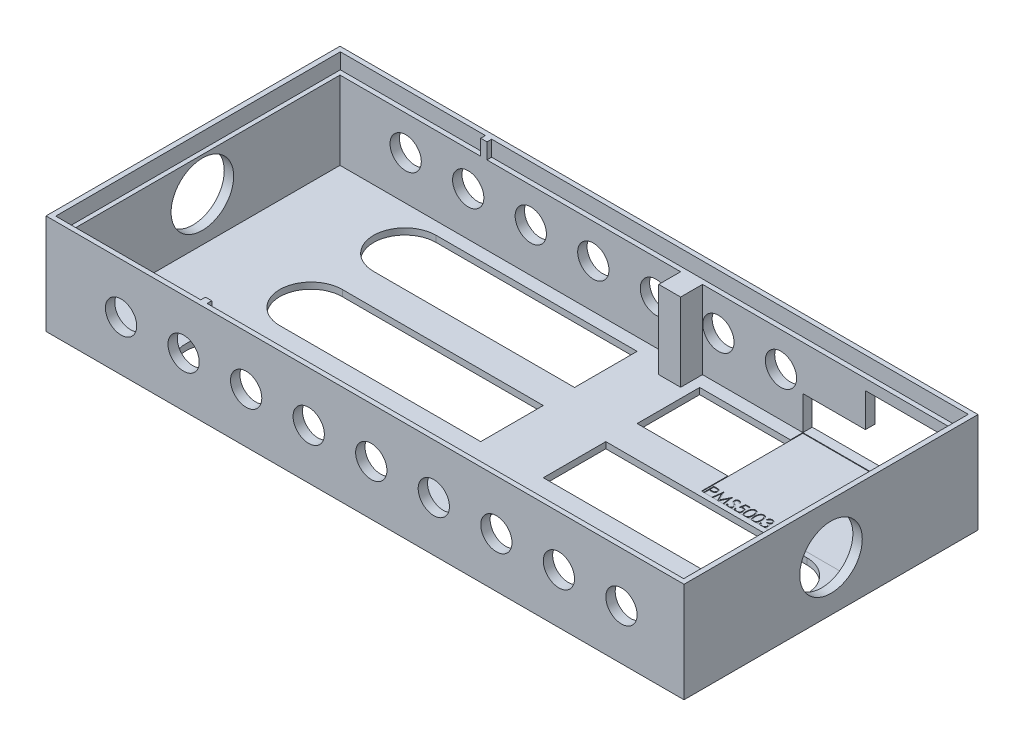
from build123d import *

# Parameters (mm, degrees)
CROQUIS1_W               = 202
CROQUIS1_H               = 93
CROQUIS1_W_2             = 198
CROQUIS1_H_2             = 88
SALIENTE_EXTRUIR2_DEPTH  = 25
CROQUIS3_W               = 202
CROQUIS3_H               = 93
SALIENTE_EXTRUIR3_DEPTH  = 2
CROQUIS4_W               = 204
CROQUIS4_H               = 94
CROQUIS4_W_2             = 202
CROQUIS4_H_2             = 93
SALIENTE_EXTRUIR5_DEPTH  = 27
CROQUIS5_W               = 204
CROQUIS5_H               = 94
CROQUIS5_W_2             = 200.789516826
CROQUIS5_H_2             = 91
SALIENTE_EXTRUIR6_DEPTH  = 5
CROQUIS6_W               = 2
CROQUIS6_H               = 1.5
SALIENTE_EXTRUIR7_DEPTH  = 5
CORTAR_EXTRUIR1_DEPTH    = 5
CORTAR_EXTRUIR2_DEPTH    = 25
CORTAR_EXTRUIR3_DEPTH    = 25
CROQUIS11_R              = 5
CORTAR_EXTRUIR4_DEPTH    = 100
CROQUIS12_W              = 15.882131831
CROQUIS12_H              = 10.610834241
SALIENTE_EXTRUIR9_DEPTH  = 3
CROQUIS13_W              = 20
CROQUIS13_H              = 20
CROQUIS13_H_2            = 10
SALIENTE_EXTRUIR10_DEPTH = 2
CROQUIS14_W              = 50
CROQUIS14_H              = 27.556851467
SALIENTE_EXTRUIR11_DEPTH = 2
CORTAR_EXTRUIR5_DEPTH    = 257
CROQUIS16_W              = 7
CROQUIS16_H              = 7
SALIENTE_EXTRUIR12_DEPTH = 25
CROQUIS17_W              = 1
CROQUIS17_H              = 1
SALIENTE_EXTRUIR13_DEPTH = 25
CROQUIS18_W              = 50
CROQUIS18_H              = 32.40471897
CORTAR_EXTRUIR6_DEPTH    = 0.2
CORTAR_EXTRUIR7_DEPTH    = 0.2


with BuildPart() as part:
    # Croquis1 → Saliente-Extruir2 (new body)
    with BuildSketch(Plane(origin=(0, 0, 0), x_dir=(1, 0, 0), z_dir=(0, 1, 0))):
        Rectangle(CROQUIS1_W, CROQUIS1_H)
        Rectangle(CROQUIS1_W_2, CROQUIS1_H_2, mode=Mode.SUBTRACT)
    extrude(amount=SALIENTE_EXTRUIR2_DEPTH)

    # Croquis3 → Saliente-Extruir3 (add)
    with BuildSketch(Plane.XZ):
        Rectangle(CROQUIS3_W, CROQUIS3_H)
    extrude(amount=SALIENTE_EXTRUIR3_DEPTH)

    # Croquis4 → Saliente-Extruir5 (add)
    with BuildSketch(Plane(origin=(0, 25, 0), x_dir=(1, 0, 0), z_dir=(0, 1, 0))):
        Rectangle(CROQUIS4_W, CROQUIS4_H)
        Rectangle(CROQUIS4_W_2, CROQUIS4_H_2, mode=Mode.SUBTRACT)
    extrude(amount=-SALIENTE_EXTRUIR5_DEPTH)

    # Croquis5 → Saliente-Extruir6 (add)
    with BuildSketch(Plane(origin=(0, 25, 0), x_dir=(1, 0, 0), z_dir=(0, 1, 0))):
        Rectangle(CROQUIS5_W, CROQUIS5_H)
        Rectangle(CROQUIS5_W_2, CROQUIS5_H_2, mode=Mode.SUBTRACT)
    extrude(amount=SALIENTE_EXTRUIR6_DEPTH)

    # Croquis6 → Saliente-Extruir7 (add)
    with BuildSketch(Plane(origin=(0, 25, 0), x_dir=(1, 0, 0), z_dir=(0, 1, 0))):
        with Locations((-53.002083315, -44.75)):
            Rectangle(CROQUIS6_W, CROQUIS6_H)
        with Locations((-53.002083315, 44.75)):
            Rectangle(CROQUIS6_W, CROQUIS6_H)
    extrude(amount=SALIENTE_EXTRUIR7_DEPTH)

    # Croquis8 → Cortar-Extruir1 (cut)
    with BuildSketch(Plane(origin=(0, 0, 0), x_dir=(1, 0, 0), z_dir=(0, 1, 0))):
        with BuildLine():
            Line((84.25, -10), (-64.25, -10))
            ThreePointArc((-64.25, -10), (-74.25, 0), (-64.25, 10))
            Line((-64.25, 10), (84.25, 10))
            ThreePointArc((84.25, 10), (94.25, 0), (84.25, -10))
        make_face()
        with BuildLine():
            Line((84.25, 20), (-64.25, 20))
            ThreePointArc((-64.25, 20), (-74.25, 30), (-64.25, 40))
            Line((-64.25, 40), (84.25, 40))
            ThreePointArc((84.25, 40), (94.25, 30), (84.25, 20))
        make_face()
        with BuildLine():
            Line((84.25, -40), (-64.25, -40))
            ThreePointArc((-64.25, -40), (-74.25, -30), (-64.25, -20))
            Line((-64.25, -20), (84.25, -20))
            ThreePointArc((84.25, -20), (94.25, -30), (84.25, -40))
        make_face()
    extrude(amount=-CORTAR_EXTRUIR1_DEPTH, mode=Mode.SUBTRACT)

    # Croquis9 → Cortar-Extruir2 (cut)
    with BuildSketch(Plane.XY.offset(-44)):
        Polygon((69, 0), (99, 0), (99, 21.623699886), (69, 21.623699886), (69, 1.623699886), align=None)
    extrude(amount=-CORTAR_EXTRUIR2_DEPTH, mode=Mode.SUBTRACT)

    # Croquis10 → Cortar-Extruir3 (cut)
    with BuildSketch(Plane.XY.offset(-44)):
        Polygon((49, 10.811849943), (49, 0), (59, 10.811849943), align=None)
        Polygon((49, 0), (69, 0), (69, 10.811849943), (59, 10.811849943), align=None)
    extrude(amount=-CORTAR_EXTRUIR3_DEPTH, mode=Mode.SUBTRACT)

    # Croquis11 → Cortar-Extruir4 (cut)
    with BuildSketch(Plane.XY.offset(47)):
        with Locations((82, 14)):
            Circle(CROQUIS11_R)
        with Locations((62, 14)):
            Circle(CROQUIS11_R)
        with Locations((42, 14)):
            Circle(CROQUIS11_R)
        with Locations((22, 14)):
            Circle(CROQUIS11_R)
        with Locations((2, 14)):
            Circle(CROQUIS11_R)
        with Locations((-18, 14)):
            Circle(CROQUIS11_R)
        with Locations((-38, 14)):
            Circle(CROQUIS11_R)
        with Locations((-58, 14)):
            Circle(CROQUIS11_R)
        with Locations((-78, 14)):
            Circle(CROQUIS11_R)
    extrude(amount=-CORTAR_EXTRUIR4_DEPTH, mode=Mode.SUBTRACT)

    # Croquis12 → Saliente-Extruir9 (add)
    with BuildSketch(Plane.XY.offset(-44)):
        with Locations((61.058934085, 16.117267064)):
            Rectangle(CROQUIS12_W, CROQUIS12_H)
    extrude(amount=-SALIENTE_EXTRUIR9_DEPTH)

    # Croquis13 → Saliente-Extruir10 (add)
    with BuildSketch(Plane(origin=(0, 0, 0), x_dir=(1, 0, 0), z_dir=(0, 1, 0))):
        with Locations((10, -30)):
            Rectangle(CROQUIS13_W, CROQUIS13_H)
        with Locations((10, -5)):
            Rectangle(CROQUIS13_W, CROQUIS13_H_2)
        with Locations((10, 5)):
            Rectangle(CROQUIS13_W, CROQUIS13_H_2)
        with Locations((10, 30)):
            Rectangle(CROQUIS13_W, CROQUIS13_H)
    extrude(amount=-SALIENTE_EXTRUIR10_DEPTH)

    # Croquis14 → Saliente-Extruir11 (add)
    with BuildSketch(Plane(origin=(0, 0, 0), x_dir=(1, 0, 0), z_dir=(0, 1, 0))):
        with Locations((74, 30.221574266)):
            Rectangle(CROQUIS14_W, CROQUIS14_H)
    extrude(amount=-SALIENTE_EXTRUIR11_DEPTH)

    # Croquis15 → Cortar-Extruir5 (cut)
    with BuildSketch(Plane(origin=(102, 0, 0), x_dir=(0, 0, -1), z_dir=(1, 0, 0))):
        with BuildLine():
            ThreePointArc((10, 14), (0, 24), (-10, 14))
            Line((-10, 14), (10, 14))
        make_face()
        with BuildLine():
            Line((10, 14), (-10, 14))
            ThreePointArc((-10, 14), (0, 4), (10, 14))
        make_face()
    extrude(amount=-CORTAR_EXTRUIR5_DEPTH, mode=Mode.SUBTRACT)

    # Croquis16 → Saliente-Extruir12 (add)
    with BuildSketch(Plane(origin=(0, 0, 0), x_dir=(1, 0, 0), z_dir=(0, 1, 0))):
        with Locations((13.41498244, 40.5)):
            Rectangle(CROQUIS16_W, CROQUIS16_H)
    extrude(amount=SALIENTE_EXTRUIR12_DEPTH)

    # Croquis17 → Saliente-Extruir13 (add)
    with BuildSketch(Plane(origin=(0, 0, 0), x_dir=(1, 0, 0), z_dir=(0, 1, 0))):
        with Locations((98.5, -43.5)):
            Rectangle(CROQUIS17_W, CROQUIS17_H)
    extrude(amount=SALIENTE_EXTRUIR13_DEPTH)

    # Croquis18 → Cortar-Extruir6 (cut)
    with BuildSketch(Plane(origin=(0, 0, 0), x_dir=(1, 0, 0), z_dir=(0, 1, 0))):
        with Locations((74, 27.797640515)):
            Rectangle(CROQUIS18_W, CROQUIS18_H)
    extrude(amount=-CORTAR_EXTRUIR6_DEPTH, mode=Mode.SUBTRACT)

    # Croquis19 → Cortar-Extruir7 (cut)
    with BuildSketch(Plane(origin=(0, -0.2, 0), x_dir=(1, 0, 0), z_dir=(0, 1, 0))):
        with BuildLine():
            Line((49.448717949, 15.09528103), (50.135116186, 15.09528103))
            add(Edge.make_bspline(
                [(50.135116186, 15.09528103), (50.182327092, 15.095229134), (50.272785285, 15.095129698), (50.402500341, 15.092114952), (50.520310072, 15.08808826), (50.625960453, 15.082506367), (50.719776551, 15.075909777), (50.801333851, 15.066657738), (50.871273407, 15.056997442), (50.913179857, 15.047176036), (50.932291667, 15.042696895)],
                knots=[0, 0, 0, 0, 0.000141628, 0.000271366, 0.00038923, 0.000495248, 0.00058876, 0.000671296, 0.000741499, 0.00080036, 0.00080036, 0.00080036, 0.00080036], degree=3))
            add(Edge.make_bspline(
                [(50.932291667, 15.042696895), (50.9564852, 15.036074946), (51.004302178, 15.022987084), (51.073203221, 14.99677336), (51.138757066, 14.965691195), (51.201188625, 14.930267255), (51.259730708, 14.888981691), (51.315256749, 14.843508073), (51.367276729, 14.792796505), (51.415498121, 14.737415765), (51.459782918, 14.678295555), (51.497912601, 14.614553325), (51.529839828, 14.547262022), (51.5572231, 14.476468451), (51.576931554, 14.401578127), (51.591778454, 14.323111415), (51.601202082, 14.241076725), (51.602104643, 14.185016857), (51.602564103, 14.156478947)],
                knots=[0, 0, 0, 0, 7.5216e-05, 0.00014866, 0.000220794, 0.000292713, 0.000363707, 0.000435434, 0.000507823, 0.000581364, 0.000655543, 0.000729131, 0.000803767, 0.000878771, 0.000956497, 0.001035702, 0.001118238, 0.001203821, 0.001203821, 0.001203821, 0.001203821], degree=3))
            add(Edge.make_bspline(
                [(51.602564103, 14.156478947), (51.602142678, 14.12770117), (51.601318132, 14.071395506), (51.591421847, 13.989022718), (51.578091655, 13.910304328), (51.557594603, 13.835414877), (51.53074893, 13.764799107), (51.499256877, 13.697377875), (51.461273346, 13.634298203), (51.417628517, 13.575331085), (51.369076922, 13.520421173), (51.315823984, 13.469966378), (51.258084692, 13.42426204), (51.196042543, 13.383205696), (51.129092695, 13.347749417), (51.058250541, 13.315992112), (50.982900325, 13.289321051), (50.930757811, 13.27529099), (50.904246795, 13.268157633)],
                knots=[0, 0, 0, 0, 8.6284e-05, 0.00016882, 0.000248587, 0.000325638, 0.000401297, 0.000474998, 0.000548586, 0.000621785, 0.0006948, 0.0007682, 0.000841564, 0.000915458, 0.000991056, 0.00106858, 0.00114819, 0.001230532, 0.001230532, 0.001230532, 0.001230532], degree=3))
            add(Edge.make_bspline(
                [(50.904246795, 13.268157633), (50.882319461, 13.263494652), (50.834264434, 13.253275457), (50.755121711, 13.241867001), (50.662976325, 13.2321294), (50.557954045, 13.224828262), (50.440149141, 13.218577894), (50.309497883, 13.2136098), (50.165743806, 13.210879946), (50.065472562, 13.210739153), (50.013120994, 13.210665645)],
                knots=[0, 0, 0, 0, 6.7238e-05, 0.000147357, 0.000239727, 0.000345177, 0.000463135, 0.000593636, 0.000737393, 0.000894446, 0.000894446, 0.000894446, 0.000894446], degree=3))
            Line((50.013120994, 13.210665645), (49.762820513, 13.210665645))
            Line((49.762820513, 13.210665645), (49.762820513, 11.59528103))
            Line((49.762820513, 11.59528103), (49.448717949, 11.59528103))
            Line((49.448717949, 11.59528103), (49.448717949, 15.09528103))
        make_face()
        with BuildLine():
            Line((49.762820513, 14.736306671), (49.762820513, 13.569640004))
            Line((49.762820513, 13.569640004), (50.375600962, 13.561927665))
            add(Edge.make_bspline(
                [(50.375600962, 13.561927665), (50.405520887, 13.561912201), (50.463280687, 13.561882349), (50.546716911, 13.565867572), (50.624126198, 13.570468105), (50.695270773, 13.577204029), (50.760182708, 13.586725286), (50.818970237, 13.596337024), (50.871177519, 13.610242387), (50.932276721, 13.628965456), (51.000360069, 13.660898071), (51.074427617, 13.707247961), (51.137198204, 13.76632867), (51.1915165, 13.832756501), (51.234622378, 13.90665563), (51.266178371, 13.985724567), (51.284719528, 14.069152417), (51.287205722, 14.126240555), (51.288461538, 14.155076703)],
                knots=[0, 0, 0, 0, 8.9746e-05, 0.000173253, 0.000250533, 0.00032239, 0.000387534, 0.00044736, 0.000500926, 0.000549486, 0.000638903, 0.000725641, 0.000810488, 0.000896226, 0.000982324, 0.00106604, 0.001150757, 0.001237226, 0.001237226, 0.001237226, 0.001237226], degree=3))
            add(Edge.make_bspline(
                [(51.288461538, 14.155076703), (51.287198892, 14.183215217), (51.284688907, 14.239151099), (51.266033044, 14.321129859), (51.23468373, 14.399365564), (51.191227135, 14.472338649), (51.138486006, 14.538527453), (51.077186662, 14.59602458), (51.007473401, 14.642246283), (50.94262517, 14.672079564), (50.885023984, 14.69029484), (50.834992024, 14.70303968), (50.77850135, 14.713215287), (50.71553357, 14.721454789), (50.646576736, 14.728508251), (50.571038421, 14.733294228), (50.489204778, 14.736095684), (50.432394207, 14.736234639), (50.402944712, 14.736306671)],
                knots=[0, 0, 0, 0, 8.4371e-05, 0.000167719, 0.000250783, 0.000336277, 0.000421575, 0.000503926, 0.000587348, 0.000671427, 0.000717102, 0.000768457, 0.000826213, 0.000889178, 0.000958942, 0.001034123, 0.001116202, 0.001204546, 0.001204546, 0.001204546, 0.001204546], degree=3))
            Line((50.402944712, 14.736306671), (49.762820513, 14.736306671))
        make_face(mode=Mode.SUBTRACT)
        Polygon((52.141025641, 11.59528103), (52.603064904, 15.09528103), (52.647936699, 15.09528103), (54.092948718, 12.223486158), (55.534455128, 15.09528103), (55.580028045, 15.09528103), (56.044871795, 11.59528103), (55.729366987, 11.59528103), (55.394230769, 14.113710517), (54.130809295, 11.59528103), (54.059995994, 11.59528103), (52.791666667, 14.119319492), (52.457231571, 11.59528103), align=None)
        with BuildLine():
            Line((56.403846154, 12.270461319), (56.699719551, 12.447845133))
            add(Edge.make_bspline(
                [(56.699719551, 12.447845133), (56.727237789, 12.401780748), (56.779961669, 12.313523164), (56.867913028, 12.194265123), (56.959045939, 12.092902967), (57.054035273, 12.010026359), (57.152301221, 11.944777472), (57.254485275, 11.898575241), (57.360243086, 11.869759265), (57.432216907, 11.866259179), (57.468149038, 11.864511799)],
                knots=[0, 0, 0, 0, 0.000160901, 0.00030828, 0.000443778, 0.00056903, 0.000685513, 0.000796284, 0.00090427, 0.001011928, 0.001011928, 0.001011928, 0.001011928], degree=3))
            add(Edge.make_bspline(
                [(57.468149038, 11.864511799), (57.498835899, 11.865366472), (57.559672672, 11.867060862), (57.649234915, 11.883341664), (57.736216717, 11.908353793), (57.818825355, 11.944174725), (57.89592097, 11.98751321), (57.963527665, 12.039859388), (58.021973778, 12.098465593), (58.069782893, 12.163848248), (58.106462928, 12.234165397), (58.134654996, 12.306341348), (58.15030007, 12.381509916), (58.152656823, 12.432120379), (58.153846154, 12.457660838)],
                knots=[0, 0, 0, 0, 9.1978e-05, 0.000182347, 0.000272202, 0.000362975, 0.000451852, 0.000536835, 0.000618639, 0.000699414, 0.000778765, 0.000855983, 0.0009312, 0.001007828, 0.001007828, 0.001007828, 0.001007828], degree=3))
            add(Edge.make_bspline(
                [(58.153846154, 12.457660838), (58.152371843, 12.486801687), (58.149374785, 12.546040777), (58.124043305, 12.63344043), (58.084194058, 12.719933), (58.047431414, 12.773434265), (58.028345353, 12.801210517)],
                knots=[0, 0, 0, 0, 8.7281e-05, 0.000177429, 0.000270909, 0.000371844, 0.000371844, 0.000371844, 0.000371844], degree=3))
            add(Edge.make_bspline(
                [(58.028345353, 12.801210517), (58.012674738, 12.821257341), (57.979776244, 12.863343139), (57.923218732, 12.925988375), (57.856852617, 12.990606794), (57.782949062, 13.059665851), (57.698815973, 13.129953647), (57.607088459, 13.204821925), (57.5054246, 13.281423502), (57.434125103, 13.332796068), (57.397335737, 13.359303466)],
                knots=[0, 0, 0, 0, 7.6319e-05, 0.000160223, 0.000252933, 0.000354147, 0.000463581, 0.000581729, 0.000709336, 0.000845369, 0.000845369, 0.000845369, 0.000845369], degree=3))
            add(Edge.make_bspline(
                [(57.397335737, 13.359303466), (57.360511741, 13.385532054), (57.290107064, 13.435679116), (57.191648482, 13.5101034), (57.103604019, 13.578147269), (57.026365003, 13.640451281), (56.959965406, 13.697023886), (56.903881995, 13.747321825), (56.859543438, 13.792705386), (56.834887857, 13.822146728), (56.823818109, 13.835365165)],
                knots=[0, 0, 0, 0, 0.000135623, 0.000259301, 0.000370234, 0.000469439, 0.00055697, 0.000631911, 0.000695377, 0.00074709, 0.00074709, 0.00074709, 0.00074709], degree=3))
            add(Edge.make_bspline(
                [(56.823818109, 13.835365165), (56.808345564, 13.855966202), (56.777916727, 13.896480905), (56.737750722, 13.959805763), (56.703611559, 14.024629028), (56.676849227, 14.091124893), (56.654313008, 14.158359822), (56.639155077, 14.227211068), (56.62966368, 14.297369686), (56.628691694, 14.344583187), (56.628205128, 14.368217729)],
                knots=[0, 0, 0, 0, 7.727e-05, 0.000151962, 0.000224716, 0.000296717, 0.00036678, 0.0004372, 0.000507902, 0.000578771, 0.000578771, 0.000578771, 0.000578771], degree=3))
            add(Edge.make_bspline(
                [(56.628205128, 14.368217729), (56.629510337, 14.405247503), (56.632092857, 14.478515567), (56.653933375, 14.585546398), (56.688406268, 14.687732815), (56.736701156, 14.784063148), (56.798958509, 14.872029129), (56.871004483, 14.952642616), (56.95681597, 15.020411199), (57.050968593, 15.079623257), (57.154024965, 15.125969182), (57.262015868, 15.160930162), (57.37511294, 15.18073942), (57.451716075, 15.183582185), (57.490584936, 15.18502462)],
                knots=[0, 0, 0, 0, 0.000110999, 0.000219625, 0.000326272, 0.00043382, 0.000541574, 0.000648775, 0.000756959, 0.000868438, 0.000981703, 0.00109501, 0.001208203, 0.0013248, 0.0013248, 0.0013248, 0.0013248], degree=3))
            add(Edge.make_bspline(
                [(57.490584936, 15.18502462), (57.531829036, 15.183602068), (57.613850388, 15.180773067), (57.734499604, 15.156175536), (57.85066032, 15.115474864), (57.944103585, 15.069286206), (58.017236346, 15.02315479), (58.073009079, 14.981134966), (58.12952653, 14.932759857), (58.187244584, 14.877900611), (58.245185244, 14.81605386), (58.304208696, 14.747643171), (58.364452965, 14.673086615), (58.403208825, 14.619862115), (58.423076923, 14.592576703)],
                knots=[0, 0, 0, 0, 0.000123638, 0.000245877, 0.000367608, 0.000492088, 0.000557638, 0.000626769, 0.000701372, 0.00078072, 0.000865532, 0.000955497, 0.001051745, 0.001152989, 0.001152989, 0.001152989, 0.001152989], degree=3))
            Line((58.423076923, 14.592576703), (58.139122596, 14.377332312))
            add(Edge.make_bspline(
                [(58.139122596, 14.377332312), (58.121976664, 14.399421003), (58.088957607, 14.441958656), (58.03882812, 14.501529971), (57.991579472, 14.555946451), (57.945029072, 14.603211579), (57.901635441, 14.645913712), (57.859518398, 14.682473469), (57.819284047, 14.713249065), (57.768567136, 14.746092624), (57.704849418, 14.778649128), (57.624864882, 14.806198206), (57.541278607, 14.822753268), (57.484348975, 14.824942156), (57.455528846, 14.826050261)],
                knots=[0, 0, 0, 0, 8.3877e-05, 0.000161528, 0.000233552, 0.000299993, 0.000360485, 0.000416152, 0.000467195, 0.000512312, 0.000597287, 0.000681099, 0.000765389, 0.000851809, 0.000851809, 0.000851809, 0.000851809], degree=3))
            add(Edge.make_bspline(
                [(57.455528846, 14.826050261), (57.419372324, 14.824838561), (57.349647876, 14.822501912), (57.25065764, 14.796981926), (57.161563715, 14.756800066), (57.08501115, 14.700485088), (57.021274173, 14.633764095), (56.975168714, 14.55698524), (56.94741855, 14.472202838), (56.94403227, 14.413061181), (56.942307692, 14.382941286)],
                knots=[0, 0, 0, 0, 0.000108248, 0.000208746, 0.00030443, 0.000399793, 0.000492054, 0.00057947, 0.000666386, 0.000756591, 0.000756591, 0.000756591, 0.000756591], degree=3))
            add(Edge.make_bspline(
                [(56.942307692, 14.382941286), (56.942700819, 14.364189808), (56.943487715, 14.326656188), (56.954462513, 14.271204767), (56.968561842, 14.215893427), (56.990904473, 14.160970844), (57.021749777, 14.105476485), (57.062254953, 14.048454748), (57.113268265, 13.989403039), (57.152345277, 13.950995665), (57.172976763, 13.930717729)],
                knots=[0, 0, 0, 0, 5.616e-05, 0.000112411, 0.000169046, 0.000227244, 0.000289691, 0.000359134, 0.000436702, 0.000523463, 0.000523463, 0.000523463, 0.000523463], degree=3))
            add(Edge.make_bspline(
                [(57.172976763, 13.930717729), (57.180638135, 13.923880703), (57.198839802, 13.907637495), (57.232115728, 13.881045214), (57.276058526, 13.848242442), (57.329520728, 13.807655125), (57.393488089, 13.760573663), (57.467967645, 13.707600051), (57.552129178, 13.647014592), (57.611851094, 13.604657051), (57.643429487, 13.582260197)],
                knots=[0, 0, 0, 0, 3.0802e-05, 7.3177e-05, 0.000127725, 0.000195314, 0.000274544, 0.000365991, 0.000469501, 0.000585644, 0.000585644, 0.000585644, 0.000585644], degree=3))
            add(Edge.make_bspline(
                [(57.643429487, 13.582260197), (57.6814154, 13.554618837), (57.754969857, 13.501095175), (57.859627437, 13.420679495), (57.954521245, 13.342031727), (58.039984448, 13.26565412), (58.116861357, 13.192126027), (58.184299078, 13.120562846), (58.242984758, 13.051477274), (58.306163976, 12.962904698), (58.370721796, 12.854123614), (58.426163303, 12.720845375), (58.461121651, 12.587049055), (58.465693166, 12.497122218), (58.467948718, 12.452752985)],
                knots=[0, 0, 0, 0, 0.000140932, 0.000272896, 0.000395881, 0.000510584, 0.000616697, 0.000714904, 0.000805482, 0.000888372, 0.001041088, 0.001183793, 0.001320341, 0.001453327, 0.001453327, 0.001453327, 0.001453327], degree=3))
            add(Edge.make_bspline(
                [(58.467948718, 12.452752985), (58.46729158, 12.42137462), (58.465990065, 12.359227237), (58.451029151, 12.26797216), (58.429109486, 12.17934129), (58.396072252, 12.094430178), (58.355749094, 12.011685415), (58.304582846, 11.933277514), (58.245275161, 11.857471116), (58.177241396, 11.786287624), (58.102795494, 11.720941429), (58.024111799, 11.662812367), (57.941061526, 11.614344044), (57.854095209, 11.574793202), (57.763192873, 11.543859684), (57.668385089, 11.521446815), (57.569515578, 11.507691104), (57.502315096, 11.506263343), (57.468149038, 11.50553744)],
                knots=[0, 0, 0, 0, 9.4044e-05, 0.000186263, 0.000276729, 0.000367488, 0.000459046, 0.000552398, 0.000647774, 0.000747454, 0.000847311, 0.000944634, 0.001040472, 0.001135227, 0.001230788, 0.001328063, 0.00142712, 0.00152957, 0.00152957, 0.00152957, 0.00152957], degree=3))
            add(Edge.make_bspline(
                [(57.468149038, 11.50553744), (57.441713695, 11.506048622), (57.389175935, 11.507064547), (57.311466454, 11.516045828), (57.235326864, 11.528752931), (57.161712582, 11.548927001), (57.089675171, 11.573403978), (57.019527936, 11.603542311), (56.951236882, 11.639659512), (56.884419299, 11.680954537), (56.819245125, 11.729012282), (56.756325657, 11.784985778), (56.693596471, 11.847331283), (56.632909075, 11.917741846), (56.573035931, 11.995079929), (56.515157521, 12.080069113), (56.458075804, 12.172246466), (56.422260336, 12.237111552), (56.403846154, 12.270461319)],
                knots=[0, 0, 0, 0, 7.9276e-05, 0.000157554, 0.000234438, 0.000310629, 0.000386236, 0.000462555, 0.000539392, 0.000617798, 0.000698008, 0.000781971, 0.000870217, 0.00096315, 0.001060616, 0.001163492, 0.001271478, 0.00138575, 0.00138575, 0.00138575, 0.00138575], degree=3))
        make_face()
        with BuildLine():
            Line((61.070512821, 15.09528103), (61.070512821, 14.736306671))
            Line((61.070512821, 14.736306671), (59.880008013, 14.736306671))
            Line((59.880008013, 14.736306671), (59.69140625, 13.815733754))
            add(Edge.make_bspline(
                [(59.69140625, 13.815733754), (59.728462124, 13.825964026), (59.80025202, 13.84578356), (59.906211881, 13.86778933), (60.006804085, 13.881054774), (60.072079455, 13.882866085), (60.103665865, 13.883742569)],
                knots=[0, 0, 0, 0, 0.000115302, 0.000223379, 0.000324431, 0.000419176, 0.000419176, 0.000419176, 0.000419176], degree=3))
            add(Edge.make_bspline(
                [(60.103665865, 13.883742569), (60.142749605, 13.882896633), (60.219598002, 13.881233312), (60.332036949, 13.865261462), (60.439369843, 13.840121548), (60.541372213, 13.805001026), (60.638232763, 13.760091293), (60.729060325, 13.703991353), (60.815218238, 13.638458021), (60.895160832, 13.563113009), (60.96768514, 13.480191393), (61.03145113, 13.391033522), (61.08561372, 13.296505859), (61.129174475, 13.195705251), (61.163958809, 13.089746097), (61.187110804, 12.977513515), (61.202527513, 12.860065395), (61.204249899, 12.779760825), (61.205128205, 12.738810677)],
                knots=[0, 0, 0, 0, 0.00011719, 0.000230425, 0.000339944, 0.000447481, 0.000553499, 0.000659556, 0.000767111, 0.000877722, 0.000988528, 0.001097091, 0.001206056, 0.001314692, 0.001425996, 0.001539995, 0.001658004, 0.001780798, 0.001780798, 0.001780798, 0.001780798], degree=3))
            add(Edge.make_bspline(
                [(61.205128205, 12.738810677), (61.20446313, 12.710288457), (61.203141967, 12.65362947), (61.19642338, 12.569485269), (61.183487664, 12.487122436), (61.166119939, 12.406530044), (61.143577521, 12.327860672), (61.116288468, 12.250889144), (61.08289244, 12.176094537), (61.046261065, 12.102769142), (61.005014587, 12.032570635), (60.959236079, 11.966921648), (60.910870588, 11.904837367), (60.858829203, 11.846983634), (60.802628208, 11.793740616), (60.742948241, 11.744792334), (60.680265522, 11.699311004), (60.613610279, 11.659142809), (60.544467796, 11.622179853), (60.471839579, 11.591856315), (60.397378879, 11.564745787), (60.320014003, 11.54313626), (60.239920191, 11.526203705), (60.156965415, 11.514703105), (60.071584745, 11.506326667), (60.013709733, 11.50580231), (59.98447516, 11.50553744)],
                knots=[0, 0, 0, 0, 8.5583e-05, 0.000170009, 0.000253005, 0.000335518, 0.000417186, 0.000498352, 0.000580291, 0.000662755, 0.000744161, 0.000824288, 0.000902692, 0.000980133, 0.001057498, 0.001134702, 0.00121156, 0.001289599, 0.001368002, 0.001446531, 0.001525481, 0.001605609, 0.001687289, 0.001770875, 0.001856759, 0.001944425, 0.001944425, 0.001944425, 0.001944425], degree=3))
            add(Edge.make_bspline(
                [(59.98447516, 11.50553744), (59.94960098, 11.506228278), (59.880990149, 11.50758742), (59.780469582, 11.521805906), (59.683754976, 11.542169822), (59.591624875, 11.572806092), (59.503253611, 11.611193387), (59.419830893, 11.659709558), (59.339225117, 11.714688662), (59.264713081, 11.779569015), (59.195556967, 11.850484697), (59.133650458, 11.927442338), (59.078516882, 12.00917178), (59.031039135, 12.096069934), (58.990541113, 12.187908465), (58.958726125, 12.285031466), (58.93304777, 12.38693147), (58.92218435, 12.45708498), (58.916666667, 12.492716927)],
                knots=[0, 0, 0, 0, 0.000104552, 0.000205693, 0.000304023, 0.000400691, 0.00049644, 0.000592535, 0.000689779, 0.000788716, 0.000888377, 0.000986596, 0.001084603, 0.001183757, 0.001283279, 0.001385267, 0.001490017, 0.001598135, 0.001598135, 0.001598135, 0.001598135], degree=3))
            Line((58.916666667, 12.492716927), (59.230769231, 12.492716927))
            add(Edge.make_bspline(
                [(59.230769231, 12.492716927), (59.238497788, 12.459340475), (59.253352505, 12.39518908), (59.285958253, 12.305057739), (59.325824129, 12.224738515), (59.373228477, 12.153168932), (59.429778508, 12.090759935), (59.494307937, 12.035142873), (59.56665566, 11.984967743), (59.647048889, 11.943144976), (59.731861969, 11.907476223), (59.820629179, 11.883724528), (59.910933525, 11.867023635), (59.972011895, 11.865351874), (60.002704327, 11.864511799)],
                knots=[0, 0, 0, 0, 0.000102709, 0.000197412, 0.000286774, 0.000371169, 0.000454082, 0.000538572, 0.000626283, 0.000717552, 0.000809994, 0.00090168, 0.00099274, 0.001084718, 0.001084718, 0.001084718, 0.001084718], degree=3))
            add(Edge.make_bspline(
                [(60.002704327, 11.864511799), (60.032662771, 11.865332577), (60.091651194, 11.866948696), (60.17846258, 11.879387708), (60.262275454, 11.898545279), (60.342262811, 11.927215134), (60.419824351, 11.962059852), (60.492998121, 12.006774928), (60.563900998, 12.058234947), (60.630329132, 12.117191577), (60.691168581, 12.182161271), (60.744924702, 12.251638665), (60.789701616, 12.325755511), (60.827435725, 12.403228664), (60.856089023, 12.484907221), (60.876530005, 12.570408397), (60.888533063, 12.659943377), (60.890184243, 12.721012686), (60.891025641, 12.752131992)],
                knots=[0, 0, 0, 0, 8.9842e-05, 0.0001769, 0.000262612, 0.000347317, 0.000431396, 0.000517249, 0.000604055, 0.000693954, 0.000783242, 0.000870748, 0.000956963, 0.001042571, 0.001128832, 0.00121607, 0.001305907, 0.001399251, 0.001399251, 0.001399251, 0.001399251], degree=3))
            add(Edge.make_bspline(
                [(60.891025641, 12.752131992), (60.890367162, 12.780207743), (60.889078282, 12.835162032), (60.878547711, 12.915561239), (60.860230739, 12.991634281), (60.834806859, 13.063748515), (60.802527351, 13.131971957), (60.763081039, 13.196375018), (60.715727641, 13.256108851), (60.661635753, 13.311201404), (60.602377712, 13.362046279), (60.536933969, 13.405390366), (60.466674042, 13.441854283), (60.392444443, 13.473322282), (60.312479544, 13.495923027), (60.228362912, 13.512890913), (60.139186204, 13.522706275), (60.078215516, 13.524068164), (60.046875, 13.52476821)],
                knots=[0, 0, 0, 0, 8.4208e-05, 0.000164824, 0.000242709, 0.000318547, 0.000393815, 0.000468731, 0.000544614, 0.00062196, 0.000700062, 0.000778428, 0.000856831, 0.000937299, 0.001019835, 0.001105635, 0.00119452, 0.001288536, 0.001288536, 0.001288536, 0.001288536], degree=3))
            add(Edge.make_bspline(
                [(60.046875, 13.52476821), (60.019746071, 13.524187618), (59.963731716, 13.522988845), (59.877808889, 13.514162348), (59.787517166, 13.499923054), (59.693202671, 13.480336806), (59.594582163, 13.454705729), (59.491863762, 13.423991229), (59.384831495, 13.38726923), (59.312713771, 13.359537016), (59.275641026, 13.34528103)],
                knots=[0, 0, 0, 0, 8.1378e-05, 0.000168026, 0.000258858, 0.000355524, 0.000456875, 0.000564457, 0.000677092, 0.000796243, 0.000796243, 0.000796243, 0.000796243], degree=3))
            Line((59.275641026, 13.34528103), (59.634615385, 15.09528103))
            Line((59.634615385, 15.09528103), (61.070512821, 15.09528103))
        make_face()
        with BuildLine():
            add(Edge.make_bspline(
                [(61.564102564, 13.343878786), (61.564430582, 13.399976174), (61.565067762, 13.508946158), (61.572156183, 13.667730801), (61.583931526, 13.81669109), (61.600068898, 13.955834156), (61.619706879, 14.08519592), (61.645922365, 14.204430677), (61.675735168, 14.314090284), (61.710287614, 14.414532332), (61.749275403, 14.507110035), (61.791709663, 14.593535237), (61.839274458, 14.673677169), (61.889251371, 14.748814959), (61.943663442, 14.817718654), (62.000962233, 14.881361317), (62.063384109, 14.938272067), (62.128807117, 14.99011837), (62.197823582, 15.035567841), (62.268466248, 15.07560058), (62.341221354, 15.109800447), (62.416287537, 15.136690883), (62.492990095, 15.15890173), (62.571597161, 15.174090677), (62.652238525, 15.183647586), (62.70666996, 15.184561254), (62.73427484, 15.18502462)],
                knots=[0, 0, 0, 0, 0.000168282, 0.000326891, 0.000476705, 0.00061646, 0.000747059, 0.00086904, 0.000982494, 0.001087814, 0.001187428, 0.001283689, 0.001376399, 0.001466822, 0.001554203, 0.001639568, 0.001723424, 0.001807301, 0.001889751, 0.001971063, 0.002050735, 0.002130583, 0.002210036, 0.002290062, 0.002370508, 0.002453288, 0.002453288, 0.002453288, 0.002453288], degree=3))
            add(Edge.make_bspline(
                [(62.73427484, 15.18502462), (62.762110318, 15.184536805), (62.817466327, 15.183566694), (62.899306702, 15.174242751), (62.979256384, 15.158771628), (63.056974523, 15.136850654), (63.133099509, 15.109654977), (63.207035917, 15.07556786), (63.279242999, 15.035888992), (63.348573286, 14.989265115), (63.415787901, 14.937282839), (63.479235864, 14.87852017), (63.53892295, 14.813570451), (63.595598256, 14.743128587), (63.647653853, 14.665843502), (63.697227285, 14.583059392), (63.741599321, 14.493328527), (63.784333996, 14.39814806), (63.821220983, 14.294884401), (63.854487228, 14.18411964), (63.881366197, 14.064545453), (63.903755469, 13.936789208), (63.921100365, 13.800381725), (63.933733007, 13.655615409), (63.940406092, 13.502395019), (63.941662793, 13.39763717), (63.942307692, 13.343878786)],
                knots=[0, 0, 0, 0, 8.3481e-05, 0.000166017, 0.000246731, 0.000327534, 0.000408041, 0.000488986, 0.000571522, 0.000654944, 0.000739373, 0.000826202, 0.000914021, 0.001003809, 0.001097153, 0.001193347, 0.001293057, 0.001397277, 0.001506176, 0.001621751, 0.001744038, 0.001873599, 0.002010742, 0.002156422, 0.002309427, 0.002470709, 0.002470709, 0.002470709, 0.002470709], degree=3))
            add(Edge.make_bspline(
                [(63.942307692, 13.343878786), (63.941656108, 13.290354879), (63.940386522, 13.186065727), (63.933807815, 13.033534751), (63.920849184, 12.889536708), (63.904639196, 12.753726246), (63.882188233, 12.626668627), (63.854583066, 12.507924178), (63.823932744, 12.396980107), (63.786097949, 12.294745295), (63.744687239, 12.199793572), (63.699632043, 12.111126424), (63.651362217, 12.027960131), (63.598773472, 11.950960384), (63.542720059, 11.879581727), (63.48200227, 11.815084104), (63.418331685, 11.755913433), (63.350919269, 11.703261805), (63.280507718, 11.657177), (63.208548641, 11.61596315), (63.133765257, 11.582730455), (63.057852305, 11.554195414), (62.979723939, 11.532394962), (62.899477548, 11.517321107), (62.817521312, 11.506749258), (62.762119747, 11.505942778), (62.73427484, 11.50553744)],
                knots=[0, 0, 0, 0, 0.000160581, 0.000312886, 0.000457868, 0.000594226, 0.000723097, 0.000844701, 0.000959884, 0.001068125, 0.001171421, 0.001270505, 0.001366343, 0.001459687, 0.001550023, 0.00163832, 0.001725149, 0.001810562, 0.001894568, 0.001977446, 0.00205903, 0.002139777, 0.00222058, 0.002301983, 0.002384599, 0.00246808, 0.00246808, 0.00246808, 0.00246808], degree=3))
            add(Edge.make_bspline(
                [(62.73427484, 11.50553744), (62.706670726, 11.506003796), (62.652240801, 11.506923358), (62.571588376, 11.516437089), (62.493305932, 11.531732592), (62.417007178, 11.553149196), (62.342300663, 11.579364033), (62.270204376, 11.613517716), (62.199916693, 11.652851785), (62.131625137, 11.697647207), (62.066612976, 11.74896889), (62.00451437, 11.805733179), (61.946889351, 11.86935659), (61.893255256, 11.938834513), (61.842281167, 12.013527755), (61.795391794, 12.094456128), (61.75202094, 12.181298739), (61.712377449, 12.27461665), (61.677228786, 12.375771577), (61.646181078, 12.485920756), (61.62166692, 12.606036392), (61.600683965, 12.735153759), (61.583759582, 12.87382769), (61.572205257, 13.022133468), (61.565063941, 13.179978677), (61.564428871, 13.288248451), (61.564102564, 13.343878786)],
                knots=[0, 0, 0, 0, 8.278e-05, 0.000163226, 0.000243252, 0.00032184, 0.00040079, 0.000480463, 0.00056082, 0.000642298, 0.000725191, 0.000809047, 0.000894412, 0.000982346, 0.001072188, 0.001165503, 0.001262704, 0.001363236, 0.001469448, 0.001583766, 0.001706286, 0.001836995, 0.001976138, 0.002125253, 0.002283161, 0.002450041, 0.002450041, 0.002450041, 0.002450041], degree=3))
        make_face()
        with BuildLine():
            add(Edge.make_bspline(
                [(61.878205128, 13.34528103), (61.878324575, 13.298532331), (61.878556399, 13.207802286), (61.884612599, 13.075959025), (61.892862831, 12.952988697), (61.903504128, 12.83873516), (61.919307077, 12.733585148), (61.937013865, 12.636815465), (61.958561954, 12.548938228), (61.984056972, 12.469350417), (62.013096069, 12.396701348), (62.044801933, 12.329100133), (62.078862656, 12.265748197), (62.116981806, 12.207214588), (62.158496869, 12.153308424), (62.202470129, 12.103075592), (62.250542713, 12.058278611), (62.317046455, 12.004551756), (62.40484293, 11.949032622), (62.515463385, 11.900686532), (62.629131836, 11.870304076), (62.706283086, 11.86644032), (62.744791667, 11.864511799)],
                knots=[0, 0, 0, 0, 0.000140231, 0.000272162, 0.000395845, 0.00050998, 0.000616273, 0.00071473, 0.000805025, 0.000887508, 0.000965234, 0.00103957, 0.001111417, 0.001180842, 0.001248855, 0.001315406, 0.001380877, 0.0014457, 0.001571746, 0.00169106, 0.001806864, 0.001922266, 0.001922266, 0.001922266, 0.001922266], degree=3))
            add(Edge.make_bspline(
                [(62.744791667, 11.864511799), (62.783549338, 11.86610958), (62.860984662, 11.869301843), (62.974118457, 11.90010058), (63.083948727, 11.94657012), (63.170020667, 12.001517625), (63.235503211, 12.053845955), (63.282420201, 12.098460603), (63.325482249, 12.14841647), (63.366324324, 12.202315766), (63.4037834, 12.26118825), (63.437846537, 12.324750826), (63.468929885, 12.393180003), (63.486638931, 12.440949743), (63.495693109, 12.465373177)],
                knots=[0, 0, 0, 0, 0.000116044, 0.000231848, 0.000349318, 0.000472837, 0.000536674, 0.000600645, 0.000666733, 0.000734322, 0.000803367, 0.000875831, 0.000950509, 0.001028633, 0.001028633, 0.001028633, 0.001028633], degree=3))
            add(Edge.make_bspline(
                [(63.495693109, 12.465373177), (63.506244877, 12.496602917), (63.527669491, 12.560012681), (63.555281265, 12.658376333), (63.577026664, 12.761579097), (63.59659003, 12.869004214), (63.609943086, 12.981443915), (63.620690899, 13.098550299), (63.627021586, 13.220411661), (63.627806337, 13.303206652), (63.628205128, 13.34528103)],
                knots=[0, 0, 0, 0, 9.8886e-05, 0.00020078, 0.000306259, 0.000415188, 0.00052824, 0.000645799, 0.000767957, 0.000894177, 0.000894177, 0.000894177, 0.000894177], degree=3))
            add(Edge.make_bspline(
                [(63.628205128, 13.34528103), (63.627654939, 13.387348603), (63.626578651, 13.469641767), (63.622464664, 13.590159948), (63.611841089, 13.704627709), (63.60004197, 13.813538182), (63.582644749, 13.916288484), (63.563886942, 14.01373879), (63.53868573, 14.104681814), (63.511765955, 14.190541396), (63.480955559, 14.270342051), (63.447039825, 14.344455837), (63.410818066, 14.413240562), (63.371475826, 14.476507503), (63.329480143, 14.534540046), (63.283722594, 14.586174641), (63.236018221, 14.633011609), (63.169201035, 14.686474178), (63.081726745, 14.740985873), (62.972881098, 14.791151633), (62.859610454, 14.819959926), (62.783037, 14.824021613), (62.744791667, 14.826050261)],
                knots=[0, 0, 0, 0, 0.000126219, 0.000246912, 0.000361616, 0.00047102, 0.00057545, 0.000674176, 0.000768567, 0.000858368, 0.000944043, 0.001024988, 0.001102772, 0.001177091, 0.00124833, 0.001317386, 0.001383826, 0.001448649, 0.001573728, 0.001692043, 0.001806995, 0.001921698, 0.001921698, 0.001921698, 0.001921698], degree=3))
            add(Edge.make_bspline(
                [(62.744791667, 14.826050261), (62.706081075, 14.824018814), (62.628589369, 14.81995222), (62.514141414, 14.791258966), (62.404437063, 14.741246001), (62.317194088, 14.686293628), (62.250330301, 14.633955317), (62.203247608, 14.588568863), (62.159101436, 14.538922608), (62.118433736, 14.484520693), (62.080344452, 14.426055326), (62.04536344, 14.363066561), (62.01384611, 14.295235197), (61.984761574, 14.222618762), (61.959188786, 14.143037817), (61.938094823, 14.055268824), (61.91860777, 13.958806932), (61.904812501, 13.853087424), (61.892548745, 13.738805271), (61.884667397, 13.615527952), (61.87853614, 13.483463572), (61.878317675, 13.392264413), (61.878205128, 13.34528103)],
                knots=[0, 0, 0, 0, 0.000116101, 0.000232413, 0.000351368, 0.000476447, 0.000540832, 0.000605795, 0.000672346, 0.000739935, 0.00080936, 0.000881545, 0.00095588, 0.001033607, 0.001116089, 0.001206384, 0.001304286, 0.001411174, 0.001526077, 0.001649061, 0.001781692, 0.001922624, 0.001922624, 0.001922624, 0.001922624], degree=3))
        make_face(mode=Mode.SUBTRACT)
        with BuildLine():
            add(Edge.make_bspline(
                [(64.256410256, 13.343878786), (64.256738275, 13.399976174), (64.257375455, 13.508946158), (64.264463876, 13.667730801), (64.276239218, 13.81669109), (64.292376591, 13.955834156), (64.312014571, 14.08519592), (64.338230057, 14.204430677), (64.36804286, 14.314090284), (64.402595306, 14.414532332), (64.441583095, 14.507110035), (64.484017356, 14.593535237), (64.53158215, 14.673677169), (64.581559063, 14.748814959), (64.635971135, 14.817718654), (64.693269925, 14.881361317), (64.755691801, 14.938272067), (64.82111481, 14.99011837), (64.890131274, 15.035567841), (64.96077394, 15.07560058), (65.033529046, 15.109800447), (65.108595229, 15.136690883), (65.185297787, 15.15890173), (65.263904854, 15.174090677), (65.344546217, 15.183647586), (65.398977652, 15.184561254), (65.426582532, 15.18502462)],
                knots=[0, 0, 0, 0, 0.000168282, 0.000326891, 0.000476705, 0.00061646, 0.000747059, 0.00086904, 0.000982494, 0.001087814, 0.001187428, 0.001283689, 0.001376399, 0.001466822, 0.001554203, 0.001639568, 0.001723424, 0.001807301, 0.001889751, 0.001971063, 0.002050735, 0.002130583, 0.002210036, 0.002290062, 0.002370508, 0.002453288, 0.002453288, 0.002453288, 0.002453288], degree=3))
            add(Edge.make_bspline(
                [(65.426582532, 15.18502462), (65.454418011, 15.184536805), (65.509774019, 15.183566694), (65.591614395, 15.174242751), (65.671564076, 15.158771628), (65.749282215, 15.136850654), (65.825407202, 15.109654977), (65.899343609, 15.07556786), (65.971550691, 15.035888992), (66.040880978, 14.989265115), (66.108095594, 14.937282839), (66.171543557, 14.87852017), (66.231230643, 14.813570451), (66.287905948, 14.743128587), (66.339961545, 14.665843502), (66.389534977, 14.583059392), (66.433907013, 14.493328527), (66.476641688, 14.39814806), (66.513528675, 14.294884401), (66.54679492, 14.18411964), (66.573673889, 14.064545453), (66.596063161, 13.936789208), (66.613408057, 13.800381725), (66.626040699, 13.655615409), (66.632713784, 13.502395019), (66.633970486, 13.39763717), (66.634615385, 13.343878786)],
                knots=[0, 0, 0, 0, 8.3481e-05, 0.000166017, 0.000246731, 0.000327534, 0.000408041, 0.000488986, 0.000571522, 0.000654944, 0.000739373, 0.000826202, 0.000914021, 0.001003809, 0.001097153, 0.001193347, 0.001293057, 0.001397277, 0.001506176, 0.001621751, 0.001744038, 0.001873599, 0.002010742, 0.002156422, 0.002309427, 0.002470709, 0.002470709, 0.002470709, 0.002470709], degree=3))
            add(Edge.make_bspline(
                [(66.634615385, 13.343878786), (66.6339638, 13.290354879), (66.632694214, 13.186065727), (66.626115507, 13.033534751), (66.613156876, 12.889536708), (66.596946888, 12.753726246), (66.574495925, 12.626668627), (66.546890759, 12.507924178), (66.516240436, 12.396980107), (66.478405642, 12.294745295), (66.436994931, 12.199793572), (66.391939735, 12.111126424), (66.343669909, 12.027960131), (66.291081164, 11.950960384), (66.235027751, 11.879581727), (66.174309962, 11.815084104), (66.110639377, 11.755913433), (66.043226961, 11.703261805), (65.97281541, 11.657177), (65.900856333, 11.61596315), (65.82607295, 11.582730455), (65.750159997, 11.554195414), (65.672031631, 11.532394962), (65.59178524, 11.517321107), (65.509829004, 11.506749258), (65.454427439, 11.505942778), (65.426582532, 11.50553744)],
                knots=[0, 0, 0, 0, 0.000160581, 0.000312886, 0.000457868, 0.000594226, 0.000723097, 0.000844701, 0.000959884, 0.001068125, 0.001171421, 0.001270505, 0.001366343, 0.001459687, 0.001550023, 0.00163832, 0.001725149, 0.001810562, 0.001894568, 0.001977446, 0.00205903, 0.002139777, 0.00222058, 0.002301983, 0.002384599, 0.00246808, 0.00246808, 0.00246808, 0.00246808], degree=3))
            add(Edge.make_bspline(
                [(65.426582532, 11.50553744), (65.398978418, 11.506003796), (65.344548493, 11.506923358), (65.263896068, 11.516437089), (65.185613624, 11.531732592), (65.10931487, 11.553149196), (65.034608355, 11.579364033), (64.962512069, 11.613517716), (64.892224385, 11.652851785), (64.823932829, 11.697647207), (64.758920668, 11.74896889), (64.696822063, 11.805733179), (64.639197043, 11.86935659), (64.585562948, 11.938834513), (64.53458886, 12.013527755), (64.487699486, 12.094456128), (64.444328632, 12.181298739), (64.404685142, 12.27461665), (64.369536478, 12.375771577), (64.33848877, 12.485920756), (64.313974613, 12.606036392), (64.292991657, 12.735153759), (64.276067274, 12.87382769), (64.264512949, 13.022133468), (64.257371634, 13.179978677), (64.256736563, 13.288248451), (64.256410256, 13.343878786)],
                knots=[0, 0, 0, 0, 8.278e-05, 0.000163226, 0.000243252, 0.00032184, 0.00040079, 0.000480463, 0.00056082, 0.000642298, 0.000725191, 0.000809047, 0.000894412, 0.000982346, 0.001072188, 0.001165503, 0.001262704, 0.001363236, 0.001469448, 0.001583766, 0.001706286, 0.001836995, 0.001976138, 0.002125253, 0.002283161, 0.002450041, 0.002450041, 0.002450041, 0.002450041], degree=3))
        make_face()
        with BuildLine():
            add(Edge.make_bspline(
                [(64.570512821, 13.34528103), (64.570632268, 13.298532331), (64.570864091, 13.207802286), (64.576920291, 13.075959025), (64.585170523, 12.952988697), (64.595811821, 12.83873516), (64.611614769, 12.733585148), (64.629321557, 12.636815465), (64.650869647, 12.548938228), (64.676364664, 12.469350417), (64.705403761, 12.396701348), (64.737109625, 12.329100133), (64.771170348, 12.265748197), (64.809289498, 12.207214588), (64.850804562, 12.153308424), (64.894777821, 12.103075592), (64.942850405, 12.058278611), (65.009354148, 12.004551756), (65.097150622, 11.949032622), (65.207771077, 11.900686532), (65.321439528, 11.870304076), (65.398590778, 11.86644032), (65.437099359, 11.864511799)],
                knots=[0, 0, 0, 0, 0.000140231, 0.000272162, 0.000395845, 0.00050998, 0.000616273, 0.00071473, 0.000805025, 0.000887508, 0.000965234, 0.00103957, 0.001111417, 0.001180842, 0.001248855, 0.001315406, 0.001380877, 0.0014457, 0.001571746, 0.00169106, 0.001806864, 0.001922266, 0.001922266, 0.001922266, 0.001922266], degree=3))
            add(Edge.make_bspline(
                [(65.437099359, 11.864511799), (65.475857031, 11.86610958), (65.553292354, 11.869301843), (65.666426149, 11.90010058), (65.776256419, 11.94657012), (65.862328359, 12.001517625), (65.927810903, 12.053845955), (65.974727893, 12.098460603), (66.017789941, 12.14841647), (66.058632016, 12.202315766), (66.096091092, 12.26118825), (66.13015423, 12.324750826), (66.161237577, 12.393180003), (66.178946623, 12.440949743), (66.188000801, 12.465373177)],
                knots=[0, 0, 0, 0, 0.000116044, 0.000231848, 0.000349318, 0.000472837, 0.000536674, 0.000600645, 0.000666733, 0.000734322, 0.000803367, 0.000875831, 0.000950509, 0.001028633, 0.001028633, 0.001028633, 0.001028633], degree=3))
            add(Edge.make_bspline(
                [(66.188000801, 12.465373177), (66.198552569, 12.496602917), (66.219977183, 12.560012681), (66.247588957, 12.658376333), (66.269334356, 12.761579097), (66.288897722, 12.869004214), (66.302250778, 12.981443915), (66.312998591, 13.098550299), (66.319329278, 13.220411661), (66.320114029, 13.303206652), (66.320512821, 13.34528103)],
                knots=[0, 0, 0, 0, 9.8886e-05, 0.00020078, 0.000306259, 0.000415188, 0.00052824, 0.000645799, 0.000767957, 0.000894177, 0.000894177, 0.000894177, 0.000894177], degree=3))
            add(Edge.make_bspline(
                [(66.320512821, 13.34528103), (66.319962631, 13.387348603), (66.318886344, 13.469641767), (66.314772356, 13.590159948), (66.304148781, 13.704627709), (66.292349662, 13.813538182), (66.274952441, 13.916288484), (66.256194634, 14.01373879), (66.230993422, 14.104681814), (66.204073647, 14.190541396), (66.173263252, 14.270342051), (66.139347517, 14.344455837), (66.103125759, 14.413240562), (66.063783518, 14.476507503), (66.021787835, 14.534540046), (65.976030286, 14.586174641), (65.928325913, 14.633011609), (65.861508727, 14.686474178), (65.774034438, 14.740985873), (65.66518879, 14.791151633), (65.551918146, 14.819959926), (65.475344692, 14.824021613), (65.437099359, 14.826050261)],
                knots=[0, 0, 0, 0, 0.000126219, 0.000246912, 0.000361616, 0.00047102, 0.00057545, 0.000674176, 0.000768567, 0.000858368, 0.000944043, 0.001024988, 0.001102772, 0.001177091, 0.00124833, 0.001317386, 0.001383826, 0.001448649, 0.001573728, 0.001692043, 0.001806995, 0.001921698, 0.001921698, 0.001921698, 0.001921698], degree=3))
            add(Edge.make_bspline(
                [(65.437099359, 14.826050261), (65.398388767, 14.824018814), (65.320897061, 14.81995222), (65.206449107, 14.791258966), (65.096744755, 14.741246001), (65.00950178, 14.686293628), (64.942637994, 14.633955317), (64.8955553, 14.588568863), (64.851409128, 14.538922608), (64.810741428, 14.484520693), (64.772652145, 14.426055326), (64.737671132, 14.363066561), (64.706153803, 14.295235197), (64.677069266, 14.222618762), (64.651496478, 14.143037817), (64.630402515, 14.055268824), (64.610915462, 13.958806932), (64.597120193, 13.853087424), (64.584856437, 13.738805271), (64.576975089, 13.615527952), (64.570843832, 13.483463572), (64.570625368, 13.392264413), (64.570512821, 13.34528103)],
                knots=[0, 0, 0, 0, 0.000116101, 0.000232413, 0.000351368, 0.000476447, 0.000540832, 0.000605795, 0.000672346, 0.000739935, 0.00080936, 0.000881545, 0.00095588, 0.001033607, 0.001116089, 0.001206384, 0.001304286, 0.001411174, 0.001526077, 0.001649061, 0.001781692, 0.001922624, 0.001922624, 0.001922624, 0.001922624], degree=3))
        make_face(mode=Mode.SUBTRACT)
        with BuildLine():
            Line((67.397435897, 14.287588722), (67.083333333, 14.287588722))
            add(Edge.make_bspline(
                [(67.083333333, 14.287588722), (67.091842884, 14.322821206), (67.10847836, 14.391697831), (67.143175933, 14.490105092), (67.180975188, 14.583228613), (67.226364293, 14.669324687), (67.275873047, 14.750123589), (67.332595769, 14.823792714), (67.393915491, 14.892205679), (67.46174044, 14.952918917), (67.532869102, 15.007896646), (67.608303722, 15.054771703), (67.686526615, 15.095095856), (67.768079748, 15.128316088), (67.85320592, 15.153341612), (67.941135543, 15.171498417), (68.032099044, 15.183289532), (68.093846634, 15.184440295), (68.125200321, 15.18502462)],
                knots=[0, 0, 0, 0, 0.000108665, 0.000212431, 0.000312691, 0.000409905, 0.000504067, 0.000596618, 0.000688443, 0.000779278, 0.000869306, 0.00095782, 0.001045306, 0.001133058, 0.001221569, 0.001311085, 0.001402223, 0.001496238, 0.001496238, 0.001496238, 0.001496238], degree=3))
            add(Edge.make_bspline(
                [(68.125200321, 15.18502462), (68.170883063, 15.18364539), (68.261252074, 15.180917014), (68.39401512, 15.156002578), (68.52204194, 15.116577445), (68.643931187, 15.062103718), (68.75714962, 14.994916405), (68.857885807, 14.914951668), (68.944774318, 14.823752367), (69.017668695, 14.723019802), (69.074743694, 14.615364293), (69.116830068, 14.504564136), (69.142451749, 14.390882164), (69.145772306, 14.314124885), (69.147435897, 14.275669652)],
                knots=[0, 0, 0, 0, 0.000136936, 0.000270885, 0.000403723, 0.000538055, 0.000670441, 0.000797677, 0.000922646, 0.001047185, 0.00116951, 0.001287103, 0.001401935, 0.001517226, 0.001517226, 0.001517226, 0.001517226], degree=3))
            add(Edge.make_bspline(
                [(69.147435897, 14.275669652), (69.146272306, 14.238662857), (69.143995339, 14.166246303), (69.124661634, 14.060524806), (69.092125371, 13.960883205), (69.047055608, 13.866902043), (68.988714058, 13.779177203), (68.918041361, 13.697511312), (68.834538699, 13.621542154), (68.771259761, 13.578022681), (68.738681891, 13.555617569)],
                knots=[0, 0, 0, 0, 0.000110957, 0.000217125, 0.000321111, 0.000424595, 0.000528824, 0.000636204, 0.000747885, 0.000866393, 0.000866393, 0.000866393, 0.000866393], degree=3))
            add(Edge.make_bspline(
                [(68.738681891, 13.555617569), (68.775913646, 13.537639397), (68.84968052, 13.502019439), (68.950231049, 13.432163682), (69.041508925, 13.351507334), (69.092412644, 13.288564682), (69.117988782, 13.256939684)],
                knots=[0, 0, 0, 0, 0.000123863, 0.000245408, 0.000366052, 0.000487879, 0.000487879, 0.000487879, 0.000487879], degree=3))
            add(Edge.make_bspline(
                [(69.117988782, 13.256939684), (69.134830124, 13.233881932), (69.16823702, 13.188144016), (69.209472554, 13.11460759), (69.246881669, 13.040256101), (69.276031888, 12.963096695), (69.298605755, 12.884023681), (69.314741787, 12.802901285), (69.324765928, 12.719663262), (69.32620148, 12.663350782), (69.326923077, 12.635044652)],
                knots=[0, 0, 0, 0, 8.5583e-05, 0.000169764, 0.000252544, 0.000335098, 0.000416766, 0.000498992, 0.000583001, 0.000667909, 0.000667909, 0.000667909, 0.000667909], degree=3))
            add(Edge.make_bspline(
                [(69.326923077, 12.635044652), (69.325128563, 12.586034931), (69.321547981, 12.488246129), (69.289543907, 12.343771407), (69.239930666, 12.202545905), (69.16947373, 12.067471066), (69.083606222, 11.941090685), (68.981448897, 11.828014376), (68.864162489, 11.730815771), (68.73335684, 11.649605543), (68.591639712, 11.584687621), (68.44006412, 11.539630178), (68.280814066, 11.510284179), (68.171606768, 11.50713731), (68.116085737, 11.50553744)],
                knots=[0, 0, 0, 0, 0.000146863, 0.000293035, 0.000441833, 0.000594857, 0.000748684, 0.000899086, 0.001050437, 0.001204129, 0.001359752, 0.001516561, 0.001677477, 0.001843893, 0.001843893, 0.001843893, 0.001843893], degree=3))
            add(Edge.make_bspline(
                [(68.116085737, 11.50553744), (68.078666437, 11.506405654), (68.005037732, 11.508114008), (67.896794233, 11.519792609), (67.793472534, 11.541122614), (67.694932936, 11.56982592), (67.6010879, 11.606217662), (67.512223795, 11.65153636), (67.427793901, 11.704847862), (67.34859495, 11.76678145), (67.274636382, 11.836062789), (67.207883658, 11.913921799), (67.147223865, 11.998919203), (67.094281226, 12.092042259), (67.046644274, 12.192087517), (67.007463317, 12.300336015), (66.972977748, 12.415820037), (66.956944284, 12.496297777), (66.948717949, 12.537588722)],
                knots=[0, 0, 0, 0, 0.000112258, 0.000220887, 0.000326076, 0.000428356, 0.000528479, 0.000627563, 0.000727152, 0.000827569, 0.00092875, 0.001030654, 0.001134734, 0.001241526, 0.001351611, 0.001466743, 0.00158655, 0.001712791, 0.001712791, 0.001712791, 0.001712791], degree=3))
            Line((66.948717949, 12.537588722), (67.262820513, 12.537588722))
            add(Edge.make_bspline(
                [(67.262820513, 12.537588722), (67.271003804, 12.510639709), (67.286921017, 12.458221537), (67.314015315, 12.382781232), (67.344883587, 12.313623179), (67.377998146, 12.250240057), (67.412776592, 12.192007654), (67.451691517, 12.140465785), (67.491860662, 12.093350583), (67.522140015, 12.066805971), (67.536959135, 12.053814684)],
                knots=[0, 0, 0, 0, 8.4487e-05, 0.000164335, 0.000240293, 0.00031148, 0.000378817, 0.000443461, 0.000505064, 0.000564113, 0.000564113, 0.000564113, 0.000564113], degree=3))
            add(Edge.make_bspline(
                [(67.536959135, 12.053814684), (67.556555711, 12.03870635), (67.595688374, 12.008536318), (67.659456605, 11.97003469), (67.726521491, 11.936673664), (67.798336165, 11.911189969), (67.873350936, 11.889612308), (67.952778301, 11.875491789), (68.035917518, 11.865803617), (68.092685282, 11.864948686), (68.121694712, 11.864511799)],
                knots=[0, 0, 0, 0, 7.418e-05, 0.000148131, 0.000223072, 0.000298488, 0.0003764, 0.000456984, 0.000540217, 0.000627201, 0.000627201, 0.000627201, 0.000627201], degree=3))
            add(Edge.make_bspline(
                [(68.121694712, 11.864511799), (68.154448214, 11.865127705), (68.218494861, 11.866332054), (68.31194972, 11.877407761), (68.400857168, 11.893538174), (68.484230094, 11.918451157), (68.563160601, 11.949232009), (68.636542251, 11.987880414), (68.705338357, 12.033225136), (68.768667762, 12.084764294), (68.82561327, 12.141185789), (68.875752783, 12.200198861), (68.918377445, 12.26155469), (68.952761023, 12.325592811), (68.979911573, 12.39204804), (68.998394774, 12.461106869), (69.011246289, 12.532204135), (69.012292901, 12.580533104), (69.012820513, 12.604896415)],
                knots=[0, 0, 0, 0, 9.822e-05, 0.00019206, 0.00028199, 0.000368957, 0.000452673, 0.000535779, 0.000617257, 0.000699492, 0.000780303, 0.000857417, 0.000931514, 0.001003978, 0.001075065, 0.001146335, 0.001218144, 0.001291145, 0.001291145, 0.001291145, 0.001291145], degree=3))
            add(Edge.make_bspline(
                [(69.012820513, 12.604896415), (69.011290211, 12.637507754), (69.008237223, 12.702568162), (68.984928643, 12.798285736), (68.946589779, 12.890509149), (68.892917268, 12.977664939), (68.827581539, 13.05844084), (68.751216632, 13.130512323), (68.663188404, 13.189982414), (68.582168535, 13.23107107), (68.510403378, 13.259108145), (68.448987994, 13.27778311), (68.380231391, 13.293596765), (68.304965042, 13.308309037), (68.222621825, 13.320830385), (68.133291387, 13.331272201), (68.036955626, 13.339627242), (67.97026446, 13.343358337), (67.935897436, 13.34528103)],
                knots=[0, 0, 0, 0, 9.7761e-05, 0.000195035, 0.000293731, 0.000396299, 0.00050098, 0.000604654, 0.000710058, 0.000818548, 0.000876487, 0.000941025, 0.001010919, 0.001088059, 0.001171055, 0.001260716, 0.001357836, 0.001461094, 0.001461094, 0.001461094, 0.001461094], degree=3))
            Line((67.935897436, 13.34528103), (67.935897436, 13.704255389))
            add(Edge.make_bspline(
                [(67.935897436, 13.704255389), (67.979198602, 13.704990193), (68.064014948, 13.706429493), (68.187909253, 13.723837503), (68.306382565, 13.747918131), (68.416809307, 13.784803323), (68.51745802, 13.82764362), (68.604777623, 13.87749583), (68.67754477, 13.932910579), (68.735405841, 13.994743188), (68.77893507, 14.061058236), (68.810761867, 14.130174894), (68.829562194, 14.202698955), (68.832071861, 14.252193622), (68.833333333, 14.277071895)],
                knots=[0, 0, 0, 0, 0.0001298, 0.000254247, 0.000374709, 0.000491998, 0.000602842, 0.000702416, 0.000792872, 0.000876214, 0.000955164, 0.001029842, 0.001103644, 0.00117823, 0.00117823, 0.00117823, 0.00117823], degree=3))
            add(Edge.make_bspline(
                [(68.833333333, 14.277071895), (68.832918922, 14.295349641), (68.832094471, 14.331712348), (68.821697194, 14.384837416), (68.806073153, 14.436338362), (68.784593423, 14.485996173), (68.755843225, 14.533466446), (68.721437238, 14.579153895), (68.680469138, 14.622797674), (68.633523691, 14.663477994), (68.583111886, 14.702247231), (68.527862111, 14.735160868), (68.469440236, 14.76330593), (68.407781581, 14.786515432), (68.342686051, 14.80397472), (68.274459493, 14.816510562), (68.20297181, 14.824348217), (68.154200078, 14.825476633), (68.129407051, 14.826050261)],
                knots=[0, 0, 0, 0, 5.4759e-05, 0.000108941, 0.000161726, 0.000216044, 0.000270754, 0.000327825, 0.00038735, 0.000449943, 0.000514025, 0.000577874, 0.000642472, 0.000708366, 0.000775209, 0.000844379, 0.000916308, 0.00099068, 0.00099068, 0.00099068, 0.00099068], degree=3))
            add(Edge.make_bspline(
                [(68.129407051, 14.826050261), (68.089555383, 14.824658899), (68.011715807, 14.821941245), (67.89950089, 14.798138232), (67.795181556, 14.760160148), (67.715442889, 14.714827129), (67.656560315, 14.670076695), (67.614483377, 14.630994309), (67.573162867, 14.587561485), (67.53531719, 14.53710311), (67.497043213, 14.483036319), (67.462198652, 14.422612638), (67.428338959, 14.357408244), (67.40793641, 14.311312609), (67.397435897, 14.287588722)],
                knots=[0, 0, 0, 0, 0.00011944, 0.000233294, 0.000342435, 0.0004514, 0.000506931, 0.000563998, 0.000623523, 0.000686492, 0.000753006, 0.000822147, 0.000895524, 0.000973336, 0.000973336, 0.000973336, 0.000973336], degree=3))
        make_face()
    extrude(amount=-CORTAR_EXTRUIR7_DEPTH, mode=Mode.SUBTRACT)


solid = part.part
